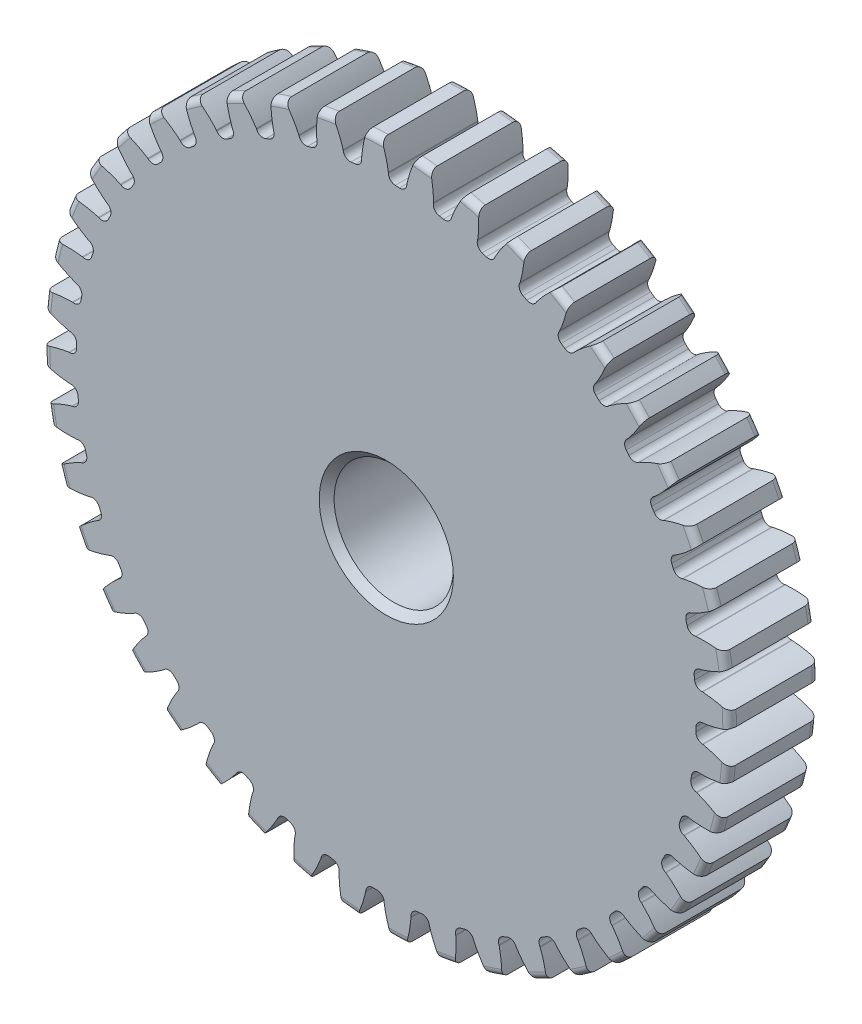
from build123d import *

# Parameters (mm, degrees)
SKETCH1_R                = 18.288
BOSS_EXTRUDE1_DEPTH      = 4.7625
SKETCH2_W                = 6.35
SKETCH2_H                = 7.9375
FILLET2_R                = 0.36576
CUT_EXTRUDE1_DEPTH       = 12.1125
FILLET1_R                = 0.37404675
CIRPATTERN1_COUNT        = 44
FILLET1_OF_CIRPATTERN1_R = 0.37404675
SKETCH5_R                = 3.175
CUT_EXTRUDE2_DEPTH       = 12.1125
CHAMFER1_SIZE            = 0.396875


with BuildPart() as part:
    # Sketch1 → Boss-Extrude1 (new body)
    with BuildSketch(Plane.XY):
        Circle(SKETCH1_R)
    extrude(amount=-BOSS_EXTRUDE1_DEPTH)

    # Sketch2 → Revolve1 (revolve)
    with BuildSketch(Plane(origin=(0, 0, 0), x_dir=(0, 0, -1), z_dir=(1, 0, 0))):
        with Locations((7.9375, 3.96875)):
            Rectangle(SKETCH2_W, SKETCH2_H)
    revolve(axis=Axis((0, 0, -4.7625), (0, 0, -1)))

    # Fillet2
    fillet2_edges = [part.edges().sort_by_distance(p)[0] for p in [
        (-18.288, 0, 0),
        (-18.288, 0, -4.7625),
        (0, -7.9375, -4.7625),
    ]]
    fillet(fillet2_edges, radius=FILLET2_R)

    # Sketch4 → Cut-Extrude1 (cut, through all)
    with BuildSketch(Plane.XY):
        with BuildLine():
            Line((0.109872383, 16.905921141), (0.109872383, 16.501696725))
            ThreePointArc((0.109872383, 16.501696725), (0.588998501, 16.49154776), (1.067627874, 16.467490321))
            Line((1.067627874, 16.467490321), (1.096464981, 16.870684814))
            add(Edge.make_bspline(
                [(3.192693422, 20.356580796), (1.548482751, 18.868075652), (1.096464981, 16.870684814)],
                knots=[0, 0, 0, 1, 1, 1], degree=2))
            ThreePointArc((3.192693422, 20.356580796), (0.735457543, 20.592298929), (-1.73233353, 20.532478991))
            add(Edge.make_bspline(
                [(-1.73233353, 20.532478991), (-0.198501128, 18.930469485), (0.109872383, 16.905921141)],
                knots=[0, 0, 0, 1, 1, 1], degree=2))
        make_face()
    cut_extrude1 = extrude(amount=-CUT_EXTRUDE1_DEPTH, mode=Mode.SUBTRACT)

    # Fillet1
    fillet1_edges = [part.edges().sort_by_distance(p)[0] for p in [
        (1.067627874, 16.467490321, -2.38125),
        (0.109872383, 16.501696725, -2.38125),
    ]]
    fillet(fillet1_edges, radius=FILLET1_R)

    # CirPattern1: Cut-Extrude1 ×44 about axis
    cirpattern1_axis = Axis((0, 0, -4.7625), (0, 0, 1))
    for i in range(1, CIRPATTERN1_COUNT):
        add(cut_extrude1.rotate(cirpattern1_axis, i * 360 / CIRPATTERN1_COUNT), mode=Mode.SUBTRACT)

    # Fillet1 of CirPattern1
    fillet1_of_cirpattern1_edges = [part.edges().sort_by_distance(p)[0] for p in [
        (-1.28680726, 16.451814302, -2.38125),
        (-2.23968226, 16.349369717, -2.38125),
        (-3.615046709, 16.101226787, -2.38125),
        (-4.543643431, 15.864216688, -2.38125),
        (-5.869694232, 15.422864727, -2.38125),
        (-6.755109125, 15.056113956, -2.38125),
        (-8.004851708, 14.430537616, -2.38125),
        (-8.829060276, 13.941512163, -2.38125),
        (-9.977053486, 13.144446374, -2.38125),
        (-10.723277222, 12.543101386, -2.38125),
        (-11.746151227, 11.59077211, -2.38125),
        (-12.399199167, 10.889349236, -2.38125),
        (-13.276131203, 9.80114315, -2.38125),
        (-13.822709173, 9.013921337, -2.38125),
        (-14.535847432, 7.811991179, -2.38125),
        (-14.964828681, 6.954995995, -2.38125),
        (-15.499655725, 5.663809597, -2.38125),
        (-15.802307433, 4.75448699, -2.38125),
        (-16.147935726, 3.400329184, -2.38125),
        (-16.318096776, 2.457190341, -2.38125),
        (-16.467490321, 1.067627874, -2.38125),
        (-16.501696725, 0.109872383, -2.38125),
        (-16.451814302, -1.28680726, -2.38125),
        (-16.349369717, -2.23968226, -2.38125),
        (-16.101226787, -3.615046709, -2.38125),
        (-15.864216688, -4.543643431, -2.38125),
        (-15.422864727, -5.869694232, -2.38125),
        (-15.056113956, -6.755109125, -2.38125),
        (-14.430537616, -8.004851708, -2.38125),
        (-13.941512163, -8.829060276, -2.38125),
        (-13.144446374, -9.977053486, -2.38125),
        (-12.543101386, -10.723277222, -2.38125),
        (-11.59077211, -11.746151227, -2.38125),
        (-10.889349236, -12.399199167, -2.38125),
        (-9.80114315, -13.276131203, -2.38125),
        (-9.013921337, -13.822709173, -2.38125),
        (-7.811991179, -14.535847432, -2.38125),
        (-6.954995995, -14.964828681, -2.38125),
        (-5.663809597, -15.499655725, -2.38125),
        (-4.75448699, -15.802307433, -2.38125),
        (-3.400329184, -16.147935726, -2.38125),
        (-2.457190341, -16.318096776, -2.38125),
        (-1.067627874, -16.467490321, -2.38125),
        (-0.109872383, -16.501696725, -2.38125),
        (1.28680726, -16.451814302, -2.38125),
        (2.23968226, -16.349369717, -2.38125),
        (3.615046709, -16.101226787, -2.38125),
        (4.543643431, -15.864216688, -2.38125),
        (5.869694232, -15.422864727, -2.38125),
        (6.755109125, -15.056113956, -2.38125),
        (8.004851708, -14.430537616, -2.38125),
        (8.829060276, -13.941512163, -2.38125),
        (9.977053486, -13.144446374, -2.38125),
        (10.723277222, -12.543101386, -2.38125),
        (11.746151227, -11.59077211, -2.38125),
        (12.399199167, -10.889349236, -2.38125),
        (13.276131203, -9.80114315, -2.38125),
        (13.822709173, -9.013921337, -2.38125),
        (14.535847432, -7.811991179, -2.38125),
        (14.964828681, -6.954995995, -2.38125),
        (15.499655725, -5.663809597, -2.38125),
        (15.802307433, -4.75448699, -2.38125),
        (16.147935726, -3.400329184, -2.38125),
        (16.318096776, -2.457190341, -2.38125),
        (16.467490321, -1.067627874, -2.38125),
        (16.501696725, -0.109872383, -2.38125),
        (16.451814302, 1.28680726, -2.38125),
        (16.349369717, 2.23968226, -2.38125),
        (16.101226787, 3.615046709, -2.38125),
        (15.864216688, 4.543643431, -2.38125),
        (15.422864727, 5.869694232, -2.38125),
        (15.056113956, 6.755109125, -2.38125),
        (14.430537616, 8.004851708, -2.38125),
        (13.941512163, 8.829060276, -2.38125),
        (13.144446374, 9.977053486, -2.38125),
        (12.543101386, 10.723277222, -2.38125),
        (11.59077211, 11.746151227, -2.38125),
        (10.889349236, 12.399199167, -2.38125),
        (9.80114315, 13.276131203, -2.38125),
        (9.013921337, 13.822709173, -2.38125),
        (7.811991179, 14.535847432, -2.38125),
        (6.954995995, 14.964828681, -2.38125),
        (5.663809597, 15.499655725, -2.38125),
        (4.75448699, 15.802307433, -2.38125),
        (3.400329184, 16.147935726, -2.38125),
        (2.457190341, 16.318096776, -2.38125),
    ]]
    fillet(fillet1_of_cirpattern1_edges, radius=FILLET1_OF_CIRPATTERN1_R)

    # Sketch5 → Cut-Extrude2 (cut, through all)
    with BuildSketch(Plane.XY):
        Circle(SKETCH5_R)
    extrude(amount=-CUT_EXTRUDE2_DEPTH, mode=Mode.SUBTRACT)

    # Chamfer1
    chamfer1_edges = [part.edges().sort_by_distance(p)[0] for p in [
        (-3.175, 0, -11.1125),
        (-3.175, 0, 0),
        (0, -7.9375, -11.1125),
    ]]
    chamfer(chamfer1_edges, length=CHAMFER1_SIZE)


solid = part.part
